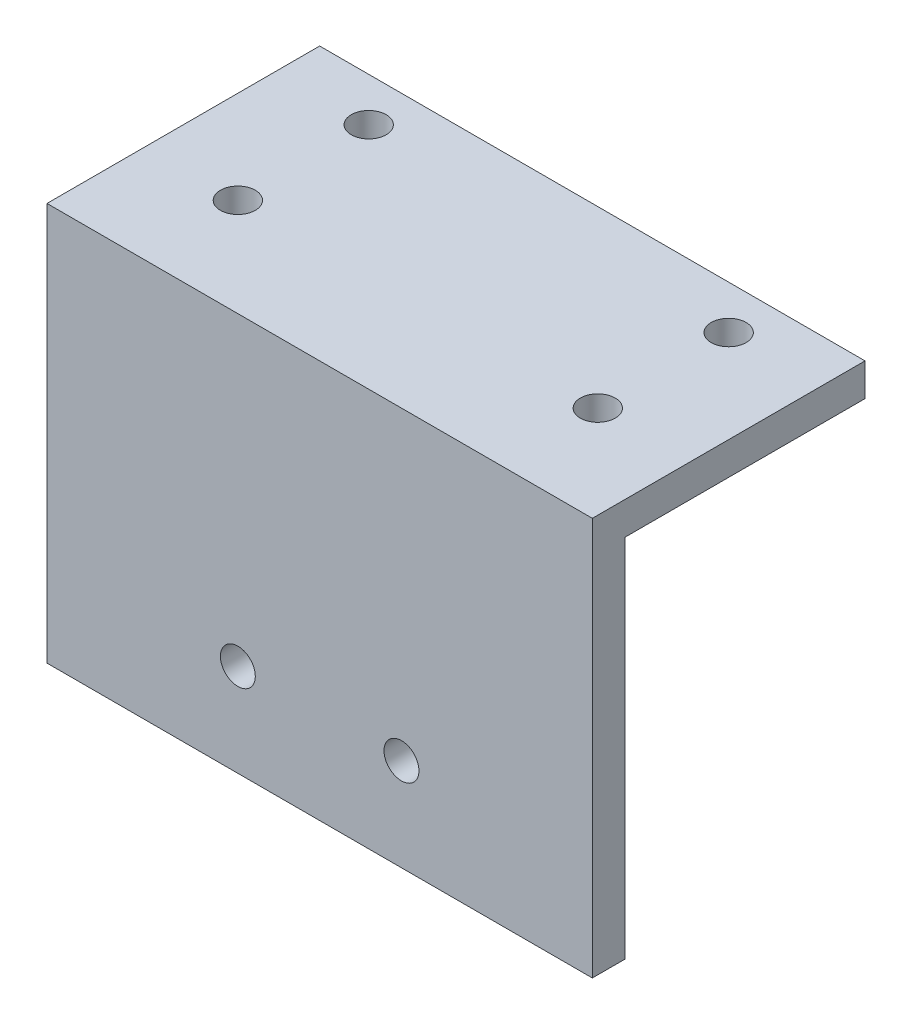
from build123d import *

# Parameters (mm, degrees)
EXTRUDE_1_DEPTH     = 50
SKETCH_2_R          = 1.6
CUT_EXTRUDE_1_DEPTH = 4
SKETCH_3_W          = 50
SKETCH_3_H          = 3
CUT_EXTRUDE_2_DEPTH = 13.5
SKETCH_4_R          = 1.6
CUT_EXTRUDE_3_DEPTH = 26


with BuildPart() as part:
    # ｽｹｯﾁ1 → ﾎﾞｽ - 押し出し1 (new body)
    with BuildSketch(Plane(origin=(0, 0, 0), x_dir=(0, 0, -1), z_dir=(1, 0, 0))):
        Polygon((0, 50), (25, 50), (25, 47), (3, 47), (3, 0), (0, 0), align=None)
    extrude(amount=EXTRUDE_1_DEPTH)

    # ｽｹｯﾁ2 → ｶｯﾄ - 押し出し1 (cut, through all)
    with BuildSketch(Plane.XZ.offset(-47)):
        with Locations((8.5, -9)):
            Circle(SKETCH_2_R)
        with Locations((8.5, -21)):
            Circle(SKETCH_2_R)
        with Locations((41.5, -9)):
            Circle(SKETCH_2_R)
        with Locations((41.5, -21)):
            Circle(SKETCH_2_R)
    extrude(amount=-CUT_EXTRUDE_1_DEPTH, mode=Mode.SUBTRACT)

    # ｽｹｯﾁ3 → ｶｯﾄ - 押し出し2 (cut)
    with BuildSketch(Plane.XZ):
        with Locations((25, -1.5)):
            Rectangle(SKETCH_3_W, SKETCH_3_H)
    extrude(amount=-CUT_EXTRUDE_2_DEPTH, mode=Mode.SUBTRACT)

    # ｽｹｯﾁ4 → ｶｯﾄ - 押し出し3 (cut, through all)
    with BuildSketch(Plane.XY):
        with Locations((17.5, 22)):
            Circle(SKETCH_4_R)
        with Locations((32.5, 22)):
            Circle(SKETCH_4_R)
    extrude(amount=-CUT_EXTRUDE_3_DEPTH, mode=Mode.SUBTRACT)


solid = part.part
